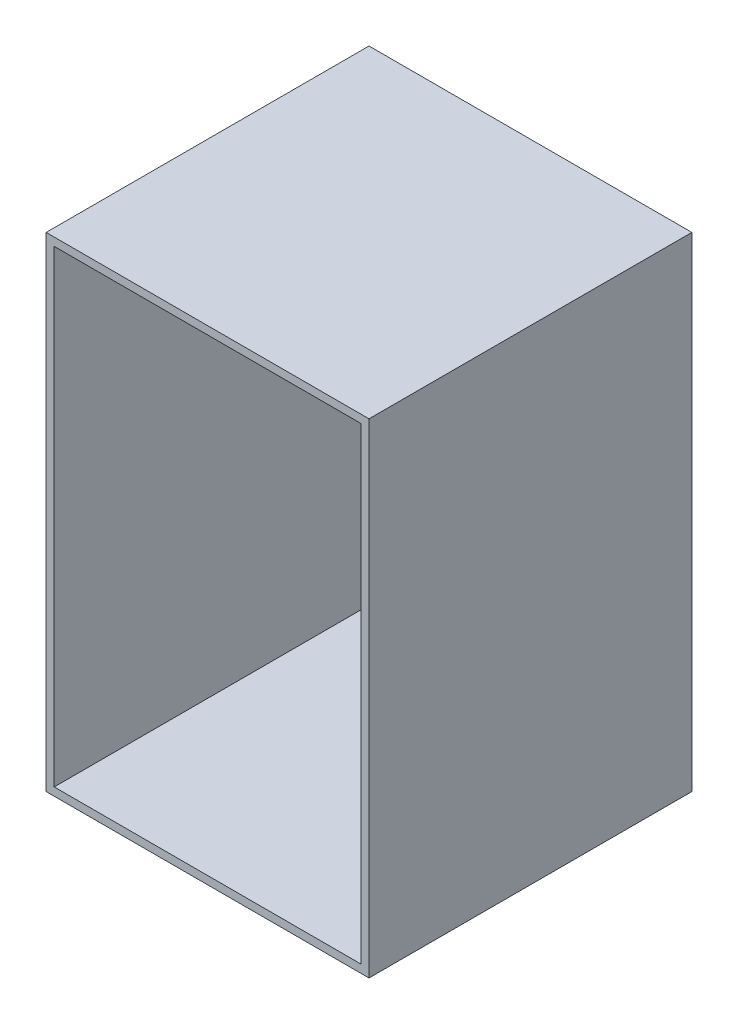
from build123d import *

# Parameters (mm, degrees)
SKETCH1_W           = 120
SKETCH1_H           = 120
BOSS_EXTRUDE1_DEPTH = 180
SHELL1_T            = -3


with BuildPart() as part:
    # Sketch1 → Boss-Extrude1 (new body)
    with BuildSketch(Plane(origin=(0, 0, 0), x_dir=(1, 0, 0), z_dir=(0, 1, 0))):
        Rectangle(SKETCH1_W, SKETCH1_H)
    extrude(amount=BOSS_EXTRUDE1_DEPTH)

    # Shell1
    shell1_openings = [part.faces().sort_by_distance(p)[0] for p in [
        (0, 90, 60),
    ]]
    offset(amount=SHELL1_T, openings=shell1_openings, kind=Kind.INTERSECTION)


solid = part.part
